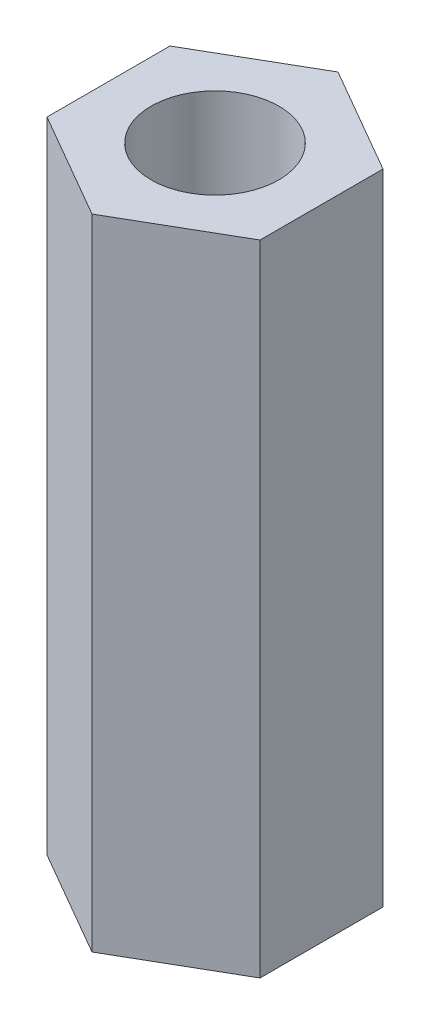
from build123d import *

# Parameters (mm, degrees)
SKETCH1_R           = 1.5
BOSS_EXTRUDE1_DEPTH = 15


with BuildPart() as part:
    # Sketch1 → Boss-Extrude1 (new body)
    with BuildSketch(Plane(origin=(0, 0, 0), x_dir=(1, 0, 0), z_dir=(0, 1, 0))):
        Polygon((-34.951809206, 17.093781707), (-37.451809206, 15.650406034), (-37.451809206, 12.763654688), (-34.951809206, 11.320279015), (-32.451809206, 12.763654688), (-32.451809206, 15.650406034), align=None)
        with Locations((-34.951809206, 14.207030361)):
            Circle(SKETCH1_R, mode=Mode.SUBTRACT)
    extrude(amount=BOSS_EXTRUDE1_DEPTH)


solid = part.part
